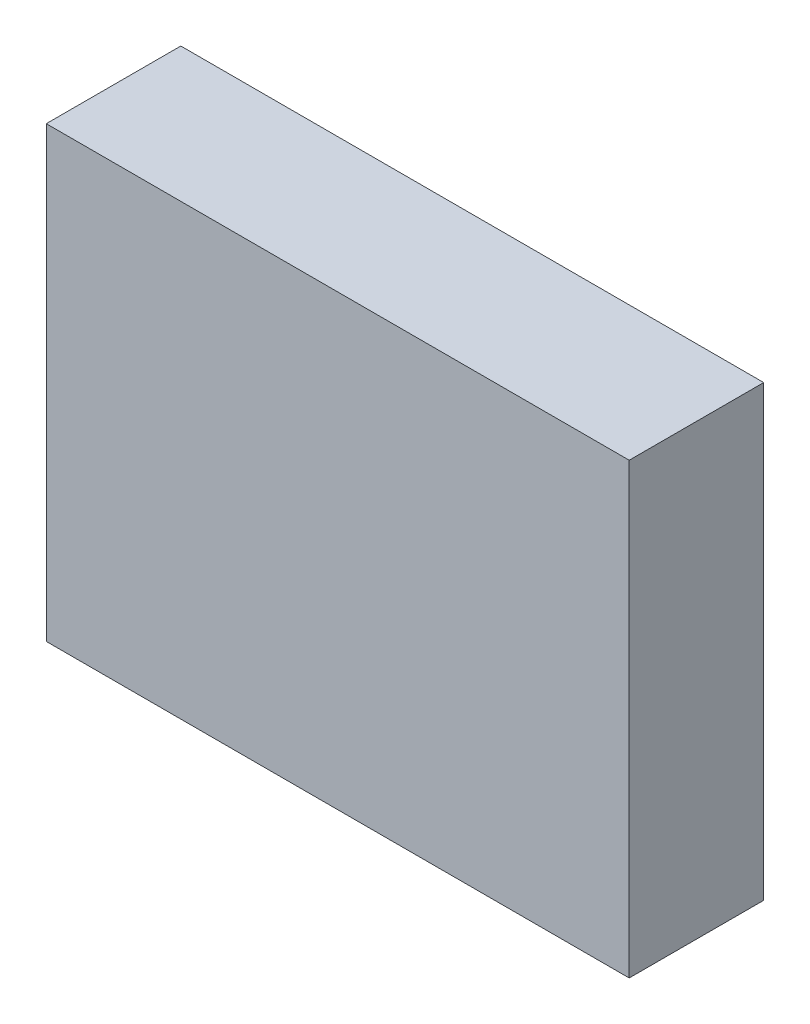
from build123d import *

# Parameters (mm, degrees)
SKETCH1_W           = 130
SKETCH1_H           = 100
BOSS_EXTRUDE1_DEPTH = 30


with BuildPart() as part:
    # Sketch1 → Boss-Extrude1 (new body)
    with BuildSketch(Plane.XY):
        Rectangle(SKETCH1_W, SKETCH1_H)
    extrude(amount=BOSS_EXTRUDE1_DEPTH)


solid = part.part
